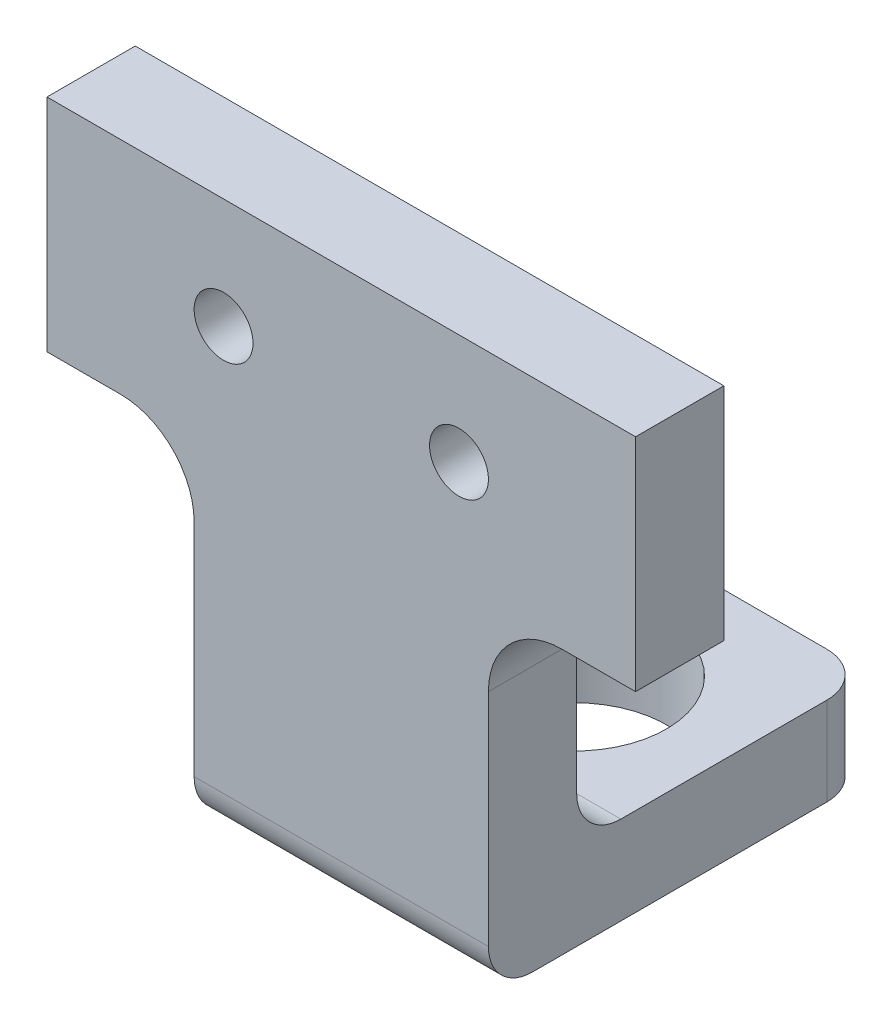
from build123d import *

# Parameters (mm, degrees)
SKETCH1_R           = 2
BOSS_EXTRUDE1_DEPTH = 6
SKETCH2_W           = 20
SKETCH2_H           = 6
BOSS_EXTRUDE2_DEPTH = 20
SKETCH3_R           = 6.25
CUT_EXTRUDE1_DEPTH  = 6
FILLET1_R           = 3
FILLET2_R           = 3
FILLET3_R           = 3


with BuildPart() as part:
    # Sketch1 → Boss-Extrude1 (new body)
    with BuildSketch(Plane.XY):
        with BuildLine():
            Line((-20, 70), (20, 70))
            Line((20, 70), (20, 55))
            Line((20, 55), (15, 55))
            ThreePointArc((15, 55), (11.464466094, 53.535533906), (10, 50))
            Line((10, 50), (10, 32))
            Line((10, 32), (-10, 32))
            Line((-10, 32), (-10, 50))
            ThreePointArc((-10, 50), (-11.464466094, 53.535533906), (-15, 55))
            Line((-15, 55), (-20, 55))
            Line((-20, 55), (-20, 70))
        make_face()
        with Locations((-8, 62.5)):
            Circle(SKETCH1_R, mode=Mode.SUBTRACT)
        with Locations((8, 62.5)):
            Circle(SKETCH1_R, mode=Mode.SUBTRACT)
    extrude(amount=BOSS_EXTRUDE1_DEPTH)

    # Sketch2 → Boss-Extrude2 (add)
    with BuildSketch(Plane(origin=(0, 0, 0), x_dir=(-1, 0, 0), z_dir=(0, 0, -1))):
        with Locations((0, 35)):
            Rectangle(SKETCH2_W, SKETCH2_H)
    extrude(amount=BOSS_EXTRUDE2_DEPTH)

    # Sketch3 → Cut-Extrude1 (cut)
    with BuildSketch(Plane(origin=(0, 38, 0), x_dir=(1, 0, 0), z_dir=(0, 1, 0))):
        with Locations((0, 9.85)):
            Circle(SKETCH3_R)
    extrude(amount=-CUT_EXTRUDE1_DEPTH, mode=Mode.SUBTRACT)

    # Fillet1
    fillet1_edges = [part.edges().sort_by_distance(p)[0] for p in [
        (10, 35, -20),
        (-10, 35, -20),
    ]]
    fillet(fillet1_edges, radius=FILLET1_R)

    # Fillet2
    fillet2_edges = [part.edges().sort_by_distance(p)[0] for p in [
        (0, 38, 0),
    ]]
    fillet(fillet2_edges, radius=FILLET2_R)

    # Fillet3
    fillet3_edges = [part.edges().sort_by_distance(p)[0] for p in [
        (0, 32, 6),
    ]]
    fillet(fillet3_edges, radius=FILLET3_R)


solid = part.part
